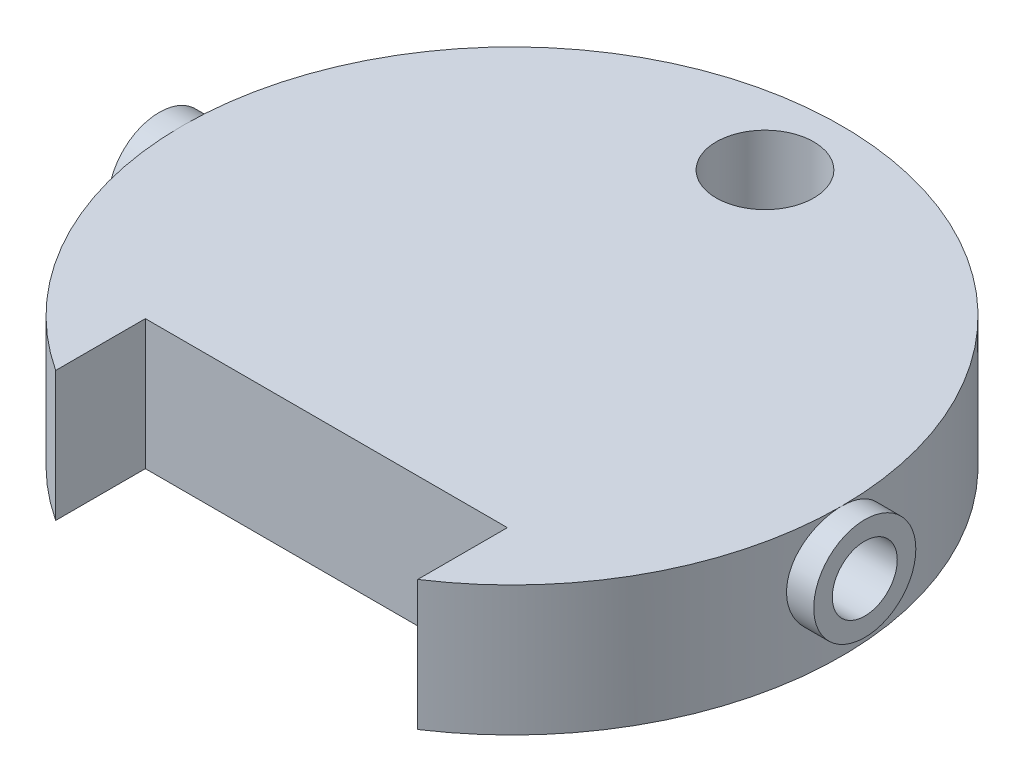
from build123d import *

# Parameters (mm, degrees)
SKETCH1_R                = 0.525
SKETCH1_W                = 5.3
SKETCH1_H                = 1
BOSS_EXTRUDE1_DEPTH      = 0.55
BOSS_EXTRUDE1_DEPTH_BACK = 0.85
SKETCH2_R                = 0.35
CUT_EXTRUDE1_DEPTH       = 4.55
CUT_EXTRUDE1_DEPTH_BACK  = 4.55
BOSS_EXTRUDE2_START      = -0.292865
SKETCH3_R                = 0.55
SKETCH3_R_2              = 0.35
BOSS_EXTRUDE2_DEPTH      = 0.292865
SKETCH5_W                = 5.3
SKETCH5_H                = 1
BOSS_EXTRUDE3_DEPTH      = 0.1


with BuildPart() as part:
    # Sketch1 → Boss-Extrude1 (new body, two sides)
    with BuildSketch(Plane(origin=(0, 0, 0), x_dir=(1, 0, 0), z_dir=(0, 1, 0))) as boss_extrude1_sk:
        with BuildLine():
            Line((-1.95, -2.966479395), (-1.95, -2))
            Line((-1.95, -2), (1.95, -2))
            Line((1.95, -2), (1.95, -2.966479395))
            ThreePointArc((1.95, -2.966479395), (2.942155057, -1.986510413), (3.480301711, -0.7))
            ThreePointArc((3.480301711, -0.7), (0, 3.55), (-3.480301711, -0.7))
            ThreePointArc((-3.480301711, -0.7), (-2.942155057, -1.986510413), (-1.95, -2.966479395))
        make_face()
        with Locations((0, 2.725)):
            Circle(SKETCH1_R, mode=Mode.SUBTRACT)
        Rectangle(SKETCH1_W, SKETCH1_H, mode=Mode.SUBTRACT)
    extrude(amount=BOSS_EXTRUDE1_DEPTH)
    extrude(boss_extrude1_sk.sketch, amount=-BOSS_EXTRUDE1_DEPTH_BACK)

    # Sketch2 → Cut-Extrude1 (cut, two sides)
    with BuildSketch(Plane(origin=(0, 0, 0), x_dir=(0, 0, -1), z_dir=(1, 0, 0))) as cut_extrude1_sk:
        Circle(SKETCH2_R)
    extrude(amount=CUT_EXTRUDE1_DEPTH, mode=Mode.SUBTRACT)
    extrude(cut_extrude1_sk.sketch, amount=-CUT_EXTRUDE1_DEPTH_BACK, mode=Mode.SUBTRACT)

    # Sketch3 → Boss-Extrude2 (add)
    with BuildSketch(Plane(origin=(3.8, 0, 0), x_dir=(0, 0, -1), z_dir=(1, 0, 0)).offset(BOSS_EXTRUDE2_START)):
        Circle(SKETCH3_R)
        Circle(SKETCH3_R_2, mode=Mode.SUBTRACT)
    boss_extrude2 = extrude(amount=BOSS_EXTRUDE2_DEPTH)

    # Mirror1: Boss-Extrude2 across plane
    add(boss_extrude2.mirror(Plane(origin=(0, 0, 0), x_dir=(0, 0, 1), z_dir=(1, 0, 0))))

    # Sketch5 → Boss-Extrude3 (add)
    with BuildSketch(Plane(origin=(0, 0.55, 0), x_dir=(1, 0, 0), z_dir=(0, 1, 0))):
        Rectangle(SKETCH5_W, SKETCH5_H)
    extrude(amount=-BOSS_EXTRUDE3_DEPTH)


solid = part.part
